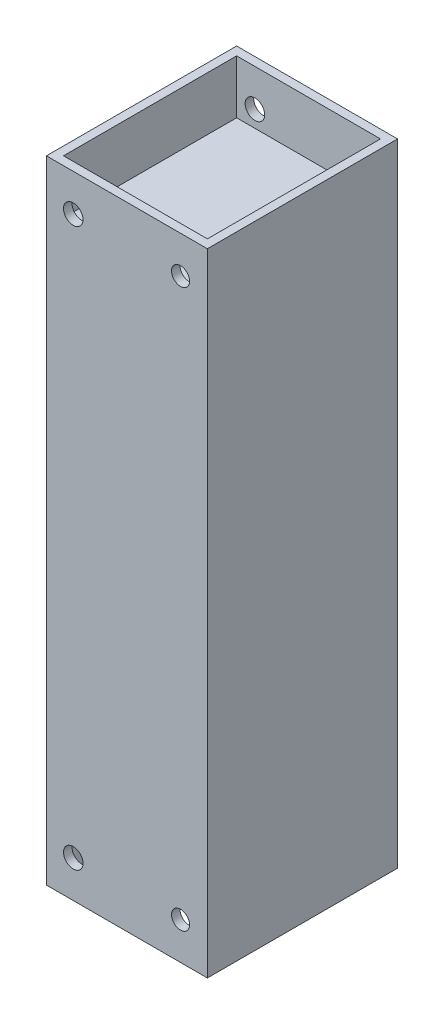
from build123d import *

# Parameters (mm, degrees)
SKETCH1_W           = 33
SKETCH1_H           = 39
BOSS_EXTRUDE1_DEPTH = 13
SKETCH2_W           = 29.5
SKETCH2_H           = 35.5
CUT_EXTRUDE1_DEPTH  = 11
SKETCH3_R           = 1.85
SKETCH3_R_2         = 2
CUT_EXTRUDE2_DEPTH  = 57
SKETCH4_W           = 33
SKETCH4_H           = 39
BOSS_EXTRUDE2_DEPTH = 51.749999878


with BuildPart() as part:
    # Sketch1 → Boss-Extrude1 (new body)
    with BuildSketch(Plane(origin=(0, 0, 0), x_dir=(1, 0, 0), z_dir=(0, 1, 0))):
        with Locations((-45.059131656, -24.092112369)):
            Rectangle(SKETCH1_W, SKETCH1_H)
    extrude(amount=BOSS_EXTRUDE1_DEPTH)

    # Sketch2 → Cut-Extrude1 (cut)
    with BuildSketch(Plane(origin=(0, 13, 0), x_dir=(1, 0, 0), z_dir=(0, 1, 0))):
        with Locations((-45.059131656, -24.092112369)):
            Rectangle(SKETCH2_W, SKETCH2_H)
    extrude(amount=-CUT_EXTRUDE1_DEPTH, mode=Mode.SUBTRACT)

    # Sketch3 → Cut-Extrude2 (cut)
    with BuildSketch(Plane.XY.offset(43.592112369)):
        with Locations((-34.059131656, 5.4)):
            Circle(SKETCH3_R)
        with Locations((-56.059131656, 5.4)):
            Circle(SKETCH3_R_2)
    extrude(amount=-CUT_EXTRUDE2_DEPTH, mode=Mode.SUBTRACT)

    # Sketch4 → Boss-Extrude2 (add)
    with BuildSketch(Plane.XZ):
        with Locations((-45.059131656, 24.092112369)):
            Rectangle(SKETCH4_W, SKETCH4_H)
    extrude(amount=BOSS_EXTRUDE2_DEPTH)

    # Mirror7: part across plane


with BuildPart() as part_1:
    add(part.part)
    add(part.part.mirror(Plane.ZX.offset(-51.749999878)))


solid = part_1.part
